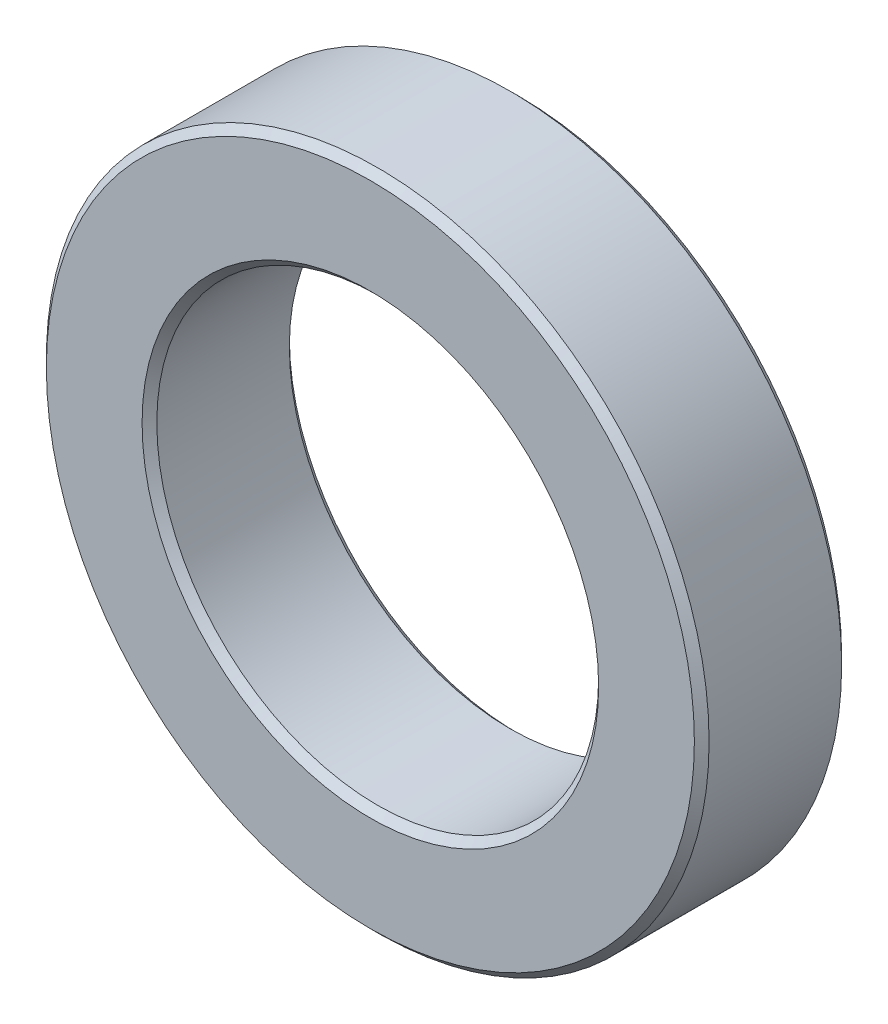
from build123d import *

# Parameters (mm, degrees)
SKETCH_1_R      = 2.25
SKETCH_1_R_2    = 1.5
EXTRUDE_1_DEPTH = 1
CHAMFER_1_SIZE  = 0.05


with BuildPart() as part:
    # 草图1 → 凸台-拉伸1 (new body)
    with BuildSketch(Plane.XY):
        Circle(SKETCH_1_R)
        Circle(SKETCH_1_R_2, mode=Mode.SUBTRACT)
    extrude(amount=EXTRUDE_1_DEPTH)

    # 倒角1
    chamfer_1_edges = [part.edges().sort_by_distance(p)[0] for p in [
        (-2.25, 0, 0),
        (-2.25, 0, 1),
        (-1.5, 0, 0),
        (-1.5, 0, 1),
    ]]
    chamfer(chamfer_1_edges, length=CHAMFER_1_SIZE)


solid = part.part
